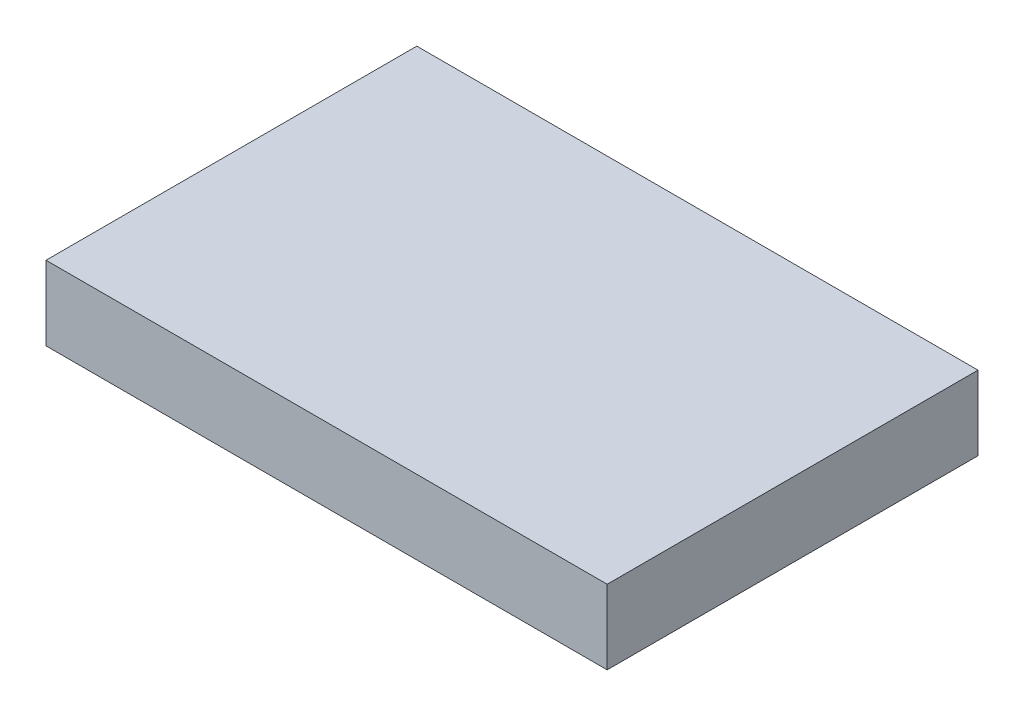
from build123d import *

# Parameters (mm, degrees)
SKETCH1_W           = 22.7
SKETCH1_H           = 15
BOSS_EXTRUDE1_DEPTH = 3


with BuildPart() as part:
    # Sketch1 → Boss-Extrude1 (new body)
    with BuildSketch(Plane(origin=(0, 0, 0), x_dir=(1, 0, 0), z_dir=(0, 1, 0))):
        with Locations((11.35, -7.5)):
            Rectangle(SKETCH1_W, SKETCH1_H)
    extrude(amount=BOSS_EXTRUDE1_DEPTH)


solid = part.part
